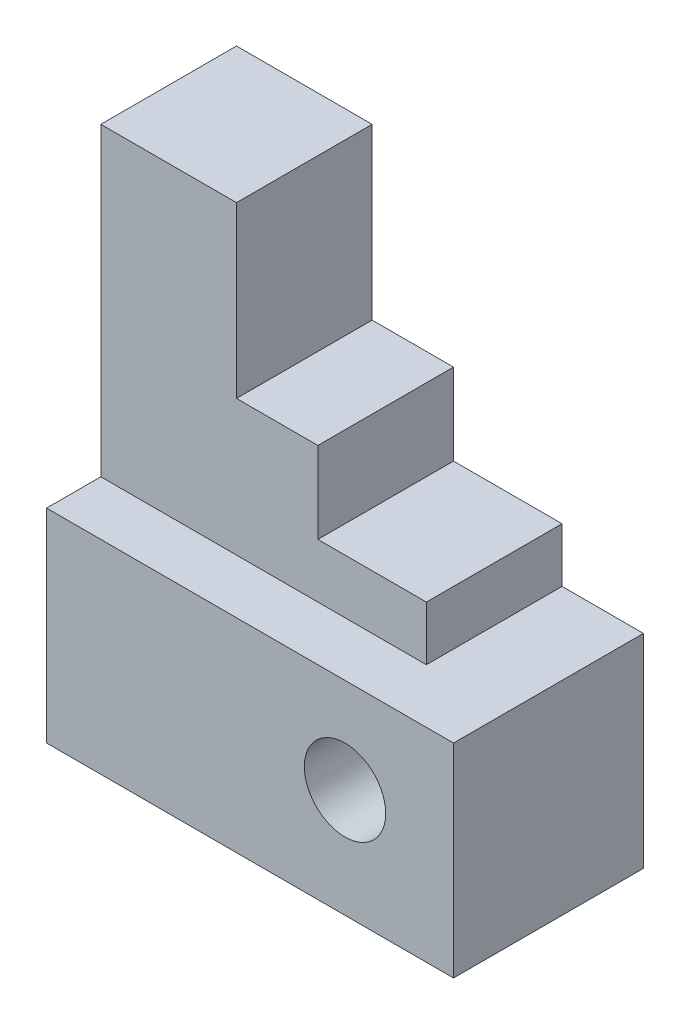
from build123d import *

# Parameters (mm, degrees)
CROQUIS2_W              = 60
CROQUIS2_H              = 30
SALIENTE_EXTRUIR1_DEPTH = 28
SALIENTE_EXTRUIR2_DEPTH = 20
CROQUIS5_R              = 6
CORTAR_EXTRUIR1_DEPTH   = 29


with BuildPart() as part:
    # Croquis2 → Saliente-Extruir1 (new body)
    with BuildSketch(Plane.XY):
        with Locations((-30, 15)):
            Rectangle(CROQUIS2_W, CROQUIS2_H)
    extrude(amount=SALIENTE_EXTRUIR1_DEPTH)

    # Croquis2_4 → Saliente-Extruir2 (add)
    with BuildSketch(Plane.XY):
        Polygon((-60, 75), (-60, 30), (-12, 30), (-12, 38), (-28, 38), (-28, 50), (-40, 50), (-40, 75), align=None)
    extrude(amount=SALIENTE_EXTRUIR2_DEPTH)

    # Croquis5 → Cortar-Extruir1 (cut, through all)
    with BuildSketch(Plane.XY.offset(28)):
        with Locations((-16, 16)):
            Circle(CROQUIS5_R)
    extrude(amount=-CORTAR_EXTRUIR1_DEPTH, mode=Mode.SUBTRACT)


solid = part.part
